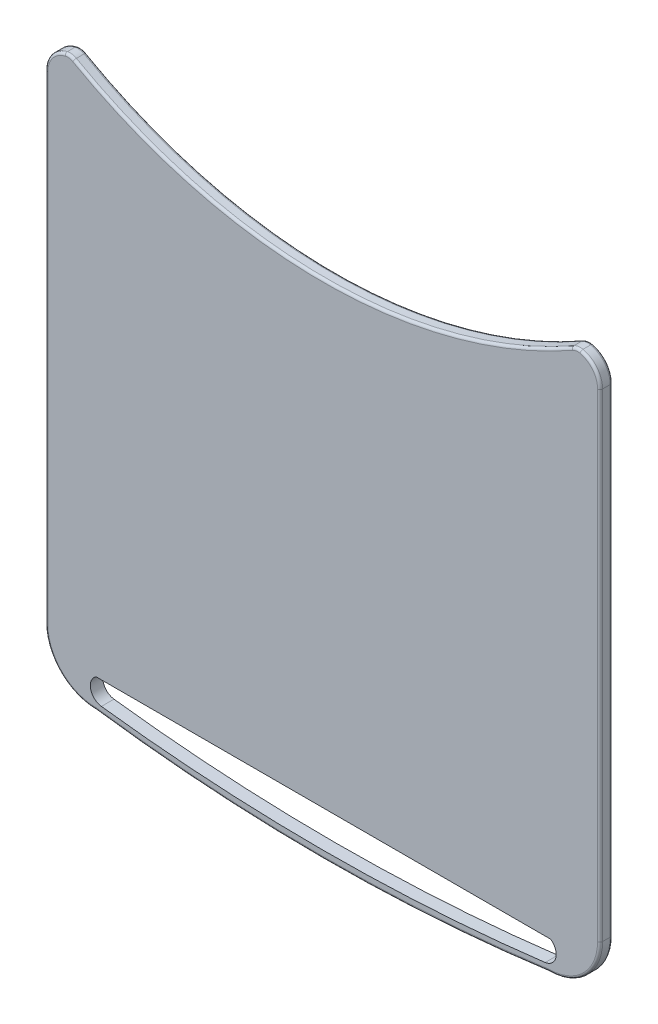
from build123d import *

# Parameters (mm, degrees)
BOSS_EXTRUDE1_DEPTH  = 5
FILLET1_R            = 1
BOSS_EXTRUDE17_DEPTH = 7
CHAMFER1_SIZE        = 6
CHAMFER2_SIZE        = 6
CHAMFER3_SIZE        = 6


with BuildPart() as part:
    # Sketch2 → Boss-Extrude1 (new body)
    with BuildSketch(Plane.XY):
        with BuildLine():
            Line((-71.683238322, 36.264064839), (-71.683238322, -153.735935161))
            ThreePointArc((-71.683238322, -153.735935161), (-65.785654561, -167.973961861), (-51.547627861, -173.871545622))
            ThreePointArc((-51.547627861, -173.871545622), (38.452372139, -179.984063939), (128.452372139, -173.871545622))
            ThreePointArc((128.452372139, -173.871545622), (142.690398839, -167.973961861), (148.5879826, -153.735935161))
            Line((148.5879826, -153.735935161), (148.5879826, 36.264064839))
            ThreePointArc((148.5879826, 36.264064839), (146.404575746, 42.501121163), (140.807808283, 46.014571182))
            ThreePointArc((140.807808283, 46.014571182), (138.971586139, 46.086284232), (137.233469629, 45.489789872))
            ThreePointArc((137.233469629, 45.489789872), (38.452372139, 19.454880614), (-60.328725351, 45.489789872))
            ThreePointArc((-60.328725351, 45.489789872), (-62.066841861, 46.086284232), (-63.903064005, 46.014571182))
            ThreePointArc((-63.903064005, 46.014571182), (-69.499831468, 42.501121163), (-71.683238322, 36.264064839))
        make_face()
        with BuildLine():
            Line((-51.547627861, -162.258832658), (128.989007395, -162.258832658))
            ThreePointArc((128.989007395, -162.258832658), (131.022308029, -167.563941455), (126.782256855, -171.345535941))
            ThreePointArc((126.782256855, -171.345535941), (38.682041526, -176.831727196), (-49.421685934, -171.402229683))
            ThreePointArc((-49.421685934, -171.402229683), (-53.676249609, -167.572612121), (-51.547627861, -162.258832658))
        make_face(mode=Mode.SUBTRACT)
    extrude(amount=BOSS_EXTRUDE1_DEPTH)

    # Fillet1
    fillet1_edges = [part.edges().sort_by_distance(p)[0] for p in [
        (38.452372139, 19.454880614, 5),
        (38.452372139, -179.984063939, 0),
        (-65.785654561, -167.973961861, 0),
        (-71.683238322, -58.735935161, 0),
        (-69.499831468, 42.501121163, 0),
        (-62.066841861, 46.086284232, 0),
        (38.452372139, 19.454880614, 0),
        (138.971586139, 46.086284232, 0),
        (146.404575746, 42.501121163, 0),
        (-62.066841861, 46.086284232, 5),
        (-69.499831468, 42.501121163, 5),
        (128.452372139, -173.871545622, 2.5),
        (-51.547627861, -173.871545622, 2.5),
        (-71.683238322, -58.735935161, 5),
        (-65.785654561, -167.973961861, 5),
        (38.452372139, -179.984063939, 5),
        (142.690398839, -167.973961861, 5),
        (148.5879826, -58.735935161, 5),
        (146.404575746, 42.501121163, 5),
        (138.971586139, 46.086284232, 5),
        (148.5879826, -58.735935161, 0),
        (142.690398839, -167.973961861, 0),
    ]]
    fillet(fillet1_edges, radius=FILLET1_R)

    # Sketch3 → Boss-Extrude17 (add)
    with BuildSketch(Plane(origin=(0, 0, 0), x_dir=(-1, 0, 0), z_dir=(0, 0, -1))):
        Polygon((-60.193398692, -12.441134496), (-80.193398692, -23.98813988), (-80.193398692, -47.082150648), (-60.193398692, -58.629156031), (-40.193398692, -47.082150648), (-40.193398692, -23.98813988), align=None)
        Polygon((-39.260340262, -48.416474981), (-59.281974378, -59.975970827), (-59.281974378, -83.094962521), (-39.260340262, -94.654458367), (-19.238706146, -83.094962521), (-19.238706146, -59.975970827), align=None)
        Polygon((-59.655195417, -84.642570383), (-79.655195417, -96.189575767), (-79.655195417, -119.283586535), (-59.655195417, -130.830591919), (-39.655195417, -119.283586535), (-39.655195417, -96.189575767), align=None)
        Polygon((-18.449927197, -84.144928283), (-38.449927197, -95.691933667), (-38.449927197, -118.785944435), (-18.449927197, -130.332949819), (1.550072803, -118.785944435), (1.550072803, -95.691933667), align=None)
        Polygon((2.303708649, -48.596386935), (-17.696291351, -60.143392319), (-17.696291351, -83.237403087), (2.303708649, -94.78440847), (22.303708649, -83.237403087), (22.303708649, -60.143392319), align=None)
        Polygon((-80.491202658, -48.737511822), (-100.491202658, -60.284517205), (-100.491202658, -83.378527973), (-80.491202658, -94.925533357), (-60.491202658, -83.378527973), (-60.491202658, -60.284517205), align=None)
        Polygon((-18.755317237, -12.540627892), (-38.755317237, -24.087633275), (-38.755317237, -47.181644043), (-18.755317237, -58.728649427), (1.244682763, -47.181644043), (1.244682763, -24.087633275), align=None)
    extrude(amount=BOSS_EXTRUDE17_DEPTH)

    # Chamfer1
    chamfer1_edges = [part.edges().sort_by_distance(p)[0] for p in [
        (70.491202658, -54.511014514, -7),
        (90.491202658, -54.511014514, -7),
        (100.491202658, -71.831522589, -7),
        (90.491202658, -89.152030665, -7),
        (70.491202658, -89.152030665, -7),
        (60.491202658, -71.831522589, -7),
    ]]
    chamfer(chamfer1_edges, length=CHAMFER1_SIZE)

    # Chamfer2
    chamfer2_edges = [part.edges().sort_by_distance(p)[0] for p in [
        (-12.303708649, -54.369889627, -7),
        (7.696291351, -54.369889627, -7),
        (17.696291351, -71.690397703, -7),
        (7.696291351, -89.010905779, -7),
        (-12.303708649, -89.010905779, -7),
        (-22.303708649, -71.690397703, -7),
    ]]
    chamfer(chamfer2_edges, length=CHAMFER2_SIZE)

    # Chamfer3
    chamfer3_edges = [part.edges().sort_by_distance(p)[0] for p in [
        (50.193398692, -18.214637188, -7),
        (70.193398692, -18.214637188, -7),
        (80.193398692, -35.535145264, -7),
        (70.193398692, -52.855653339, -7),
        (50.193398692, -52.855653339, -7),
        (40.193398692, -35.535145264, -7),
        (29.249523204, -54.196222904, -7),
        (49.27115732, -54.196222904, -7),
        (59.281974378, -71.535466674, -7),
        (49.27115732, -88.874710444, -7),
        (29.249523204, -88.874710444, -7),
        (19.238706146, -71.535466674, -7),
        (49.655195417, -90.416073075, -7),
        (69.655195417, -90.416073075, -7),
        (79.655195417, -107.736581151, -7),
        (69.655195417, -125.057089227, -7),
        (49.655195417, -125.057089227, -7),
        (39.655195417, -107.736581151, -7),
        (8.449927197, -89.918430975, -7),
        (28.449927197, -89.918430975, -7),
        (38.449927197, -107.238939051, -7),
        (28.449927197, -124.559447127, -7),
        (8.449927197, -124.559447127, -7),
        (-1.550072803, -107.238939051, -7),
        (8.755317237, -18.314130583, -7),
        (28.755317237, -18.314130583, -7),
        (38.755317237, -35.634638659, -7),
        (28.755317237, -52.955146735, -7),
        (8.755317237, -52.955146735, -7),
        (-1.244682763, -35.634638659, -7),
    ]]
    chamfer(chamfer3_edges, length=CHAMFER3_SIZE)


solid = part.part
